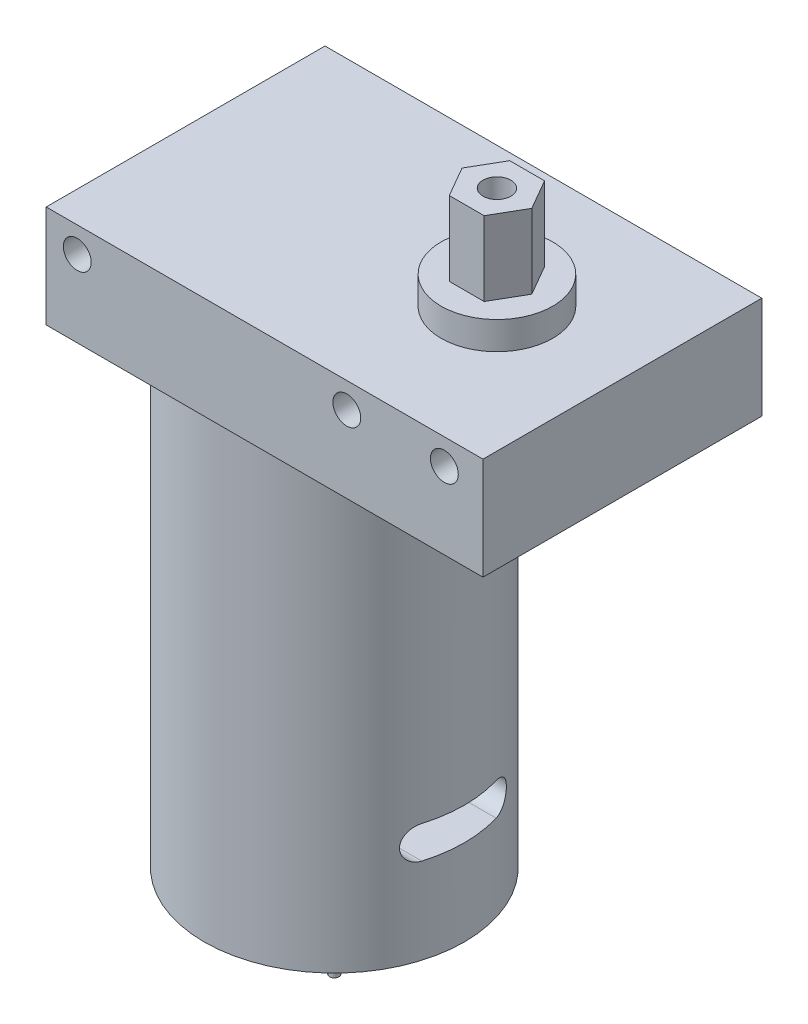
from build123d import *

# Parameters (mm, degrees)
SKETCH_1_W          = 47
SKETCH_1_H          = 30
EXTRUDE_1_DEPTH     = 11
SKETCH_2_R          = 6
EXTRUDE_2_DEPTH     = 3
EXTRUDE_3_DEPTH     = 8
SKETCH_4_R          = 14
EXTRUDE_4_DEPTH     = 50
SKETCH_5_R          = 5
EXTRUDE_5_DEPTH     = 2
SKETCH_6_R          = 1.5
CUT_EXTRUDE_1_DEPTH = 31
CUT_EXTRUDE_2_DEPTH = 48
SKETCH_9_R          = 1.5
CUT_EXTRUDE_3_DEPTH = 8
SKETCH_11_R         = 0.5
EXTRUDE_6_DEPTH     = 8


with BuildPart() as part:
    # 草图1 → 凸台-拉伸1 (new body)
    with BuildSketch(Plane(origin=(0, 0, 0), x_dir=(1, 0, 0), z_dir=(0, 1, 0))):
        with Locations((23.5, -15)):
            Rectangle(SKETCH_1_W, SKETCH_1_H)
    extrude(amount=EXTRUDE_1_DEPTH)

    # 草图2 → 凸台-拉伸2 (add)
    with BuildSketch(Plane(origin=(0, 11, 0), x_dir=(1, 0, 0), z_dir=(0, 1, 0))):
        with Locations((33.5, -15)):
            Circle(SKETCH_2_R)
    extrude(amount=EXTRUDE_2_DEPTH)

    # 草图3 → 凸台-拉伸3 (add)
    with BuildSketch(Plane(origin=(0, 14, 0), x_dir=(1, 0, 0), z_dir=(0, 1, 0))):
        Polygon((37.25277675, -15), (35.376388375, -11.75), (31.623611625, -11.75), (29.74722325, -15), (31.623611625, -18.25), (35.376388375, -18.25), align=None)
    extrude(amount=EXTRUDE_3_DEPTH)

    # 草图4 → 凸台-拉伸4 (add)
    with BuildSketch(Plane.XZ):
        with Locations((16, 15)):
            Circle(SKETCH_4_R)
    extrude(amount=EXTRUDE_4_DEPTH)

    # 草图5 → 凸台-拉伸5 (add)
    with BuildSketch(Plane.XZ.offset(50)):
        with Locations((16, 15)):
            Circle(SKETCH_5_R)
    extrude(amount=EXTRUDE_5_DEPTH)

    # 草图6 → 切除-拉伸1 (cut, through all)
    with BuildSketch(Plane.XY.offset(30)):
        with Locations((3.340757383, 8.25)):
            Circle(SKETCH_6_R)
        with Locations((32.340757383, 8.25)):
            Circle(SKETCH_6_R)
        with Locations((42.840757383, 8.25)):
            Circle(SKETCH_6_R)
    extrude(amount=-CUT_EXTRUDE_1_DEPTH, mode=Mode.SUBTRACT)

    # 草图7 → 切除-拉伸2 (cut, through all)
    with BuildSketch(Plane.ZY):
        with BuildLine():
            Line((11, -37.25), (19, -37.25))
            ThreePointArc((19, -37.25), (20.75, -39), (19, -40.75))
            Line((19, -40.75), (11, -40.75))
            ThreePointArc((11, -40.75), (9.25, -39), (11, -37.25))
        make_face()
    extrude(amount=-CUT_EXTRUDE_2_DEPTH, mode=Mode.SUBTRACT)

    # 草图9 → 切除-拉伸3 (cut)
    with BuildSketch(Plane(origin=(0, 22, 0), x_dir=(1, 0, 0), z_dir=(0, 1, 0))):
        with Locations((33.5, -15)):
            Circle(SKETCH_9_R)
    extrude(amount=-CUT_EXTRUDE_3_DEPTH, mode=Mode.SUBTRACT)

    # 草图11 → 凸台-拉伸6 (add)
    with BuildSketch(Plane.XZ.offset(52)):
        with Locations((16, 15)):
            Circle(SKETCH_11_R)
    extrude(amount=EXTRUDE_6_DEPTH)


solid = part.part
